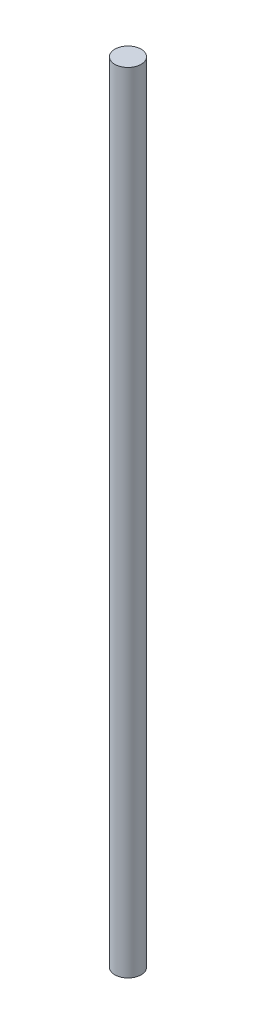
from build123d import *

# Parameters (mm, degrees)
SKETCH1_R      = 5
EXTRUDE1_DEPTH = 300


with BuildPart() as part:
    # Sketch1 → Extrude1 (new body)
    with BuildSketch(Plane(origin=(0, 0, 0), x_dir=(1, 0, 0), z_dir=(0, 1, 0))):
        Circle(SKETCH1_R)
    extrude(amount=EXTRUDE1_DEPTH)


solid = part.part
